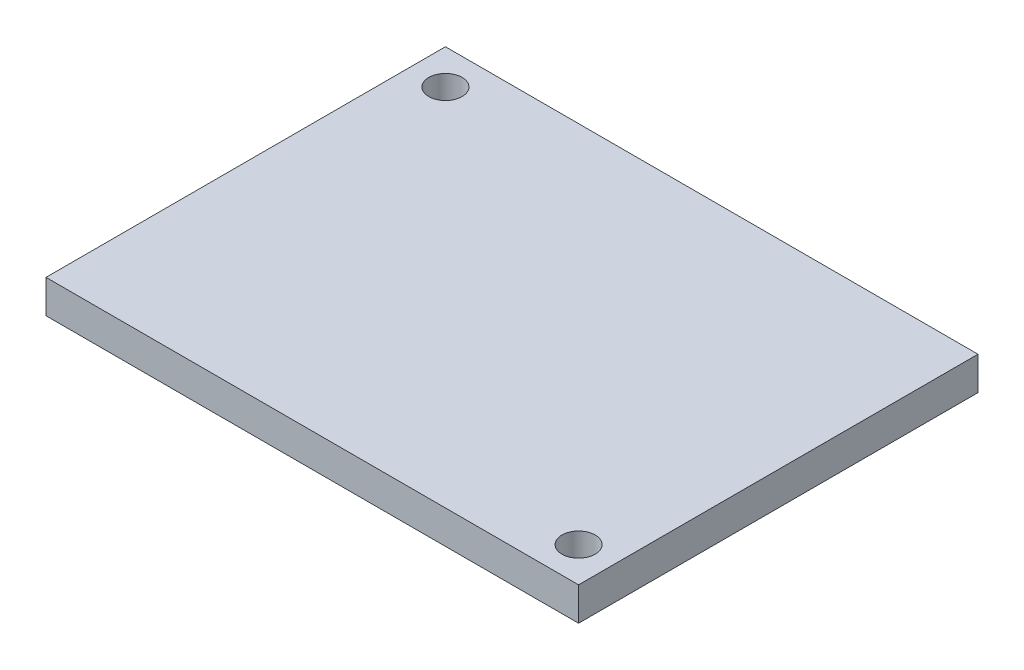
from build123d import *

# Parameters (mm, degrees)
SKETCH1_W           = 50.8
SKETCH1_H           = 38.1
SKETCH1_R           = 1.5875
BOSS_EXTRUDE1_DEPTH = 3.175


with BuildPart() as part:
    # Sketch1 → Boss-Extrude1 (new body)
    with BuildSketch(Plane(origin=(0, 0, 0), x_dir=(1, 0, 0), z_dir=(0, 1, 0))):
        Rectangle(SKETCH1_W, SKETCH1_H)
        with Locations((-22.07514, 15.72514)):
            Circle(SKETCH1_R, mode=Mode.SUBTRACT)
        with Locations((22.07514, -15.72514)):
            Circle(SKETCH1_R, mode=Mode.SUBTRACT)
    extrude(amount=BOSS_EXTRUDE1_DEPTH)


solid = part.part
